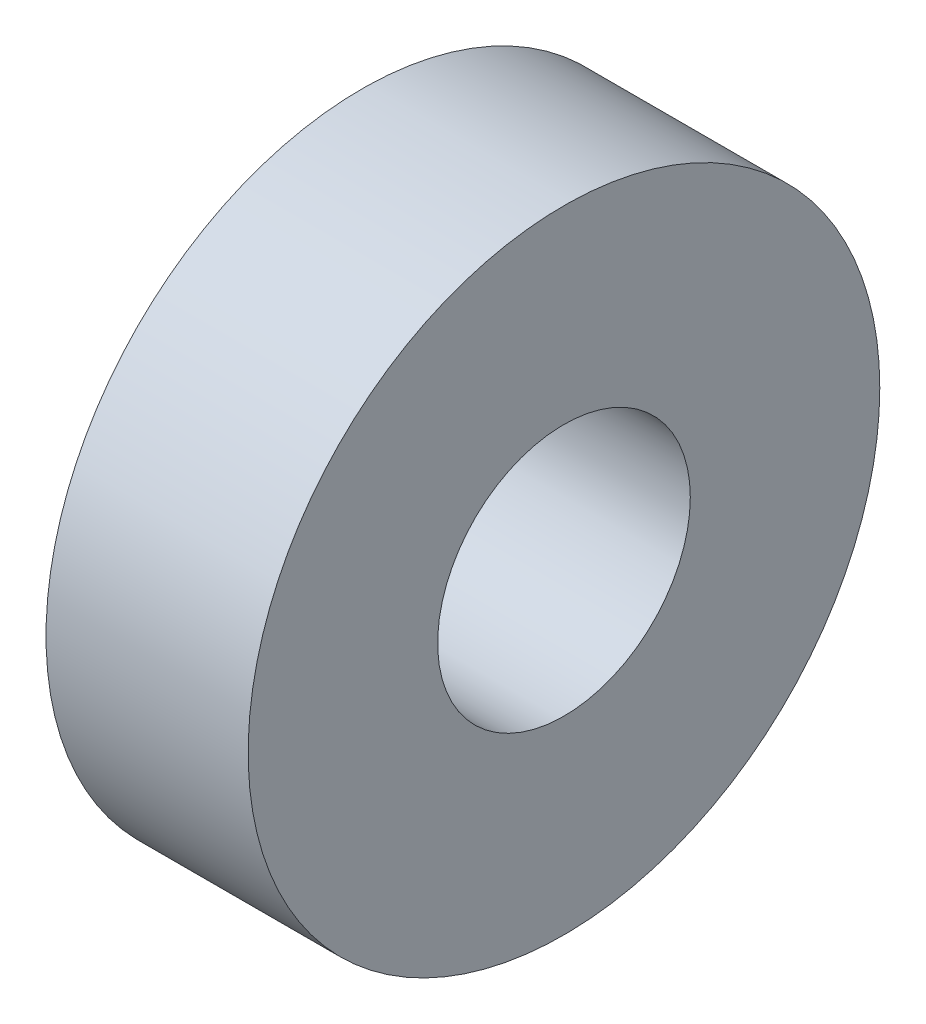
from build123d import *

# Parameters (mm, degrees)
SKETCH_1_R      = 25
SKETCH_1_R_2    = 10
EXTRUDE_1_DEPTH = 16


with BuildPart() as part:
    # 草图1 → 凸台-拉伸1 (new body)
    with BuildSketch(Plane(origin=(0, 0, 0), x_dir=(0, 0, -1), z_dir=(1, 0, 0))):
        Circle(SKETCH_1_R)
        Circle(SKETCH_1_R_2, mode=Mode.SUBTRACT)
    extrude(amount=EXTRUDE_1_DEPTH)


solid = part.part
